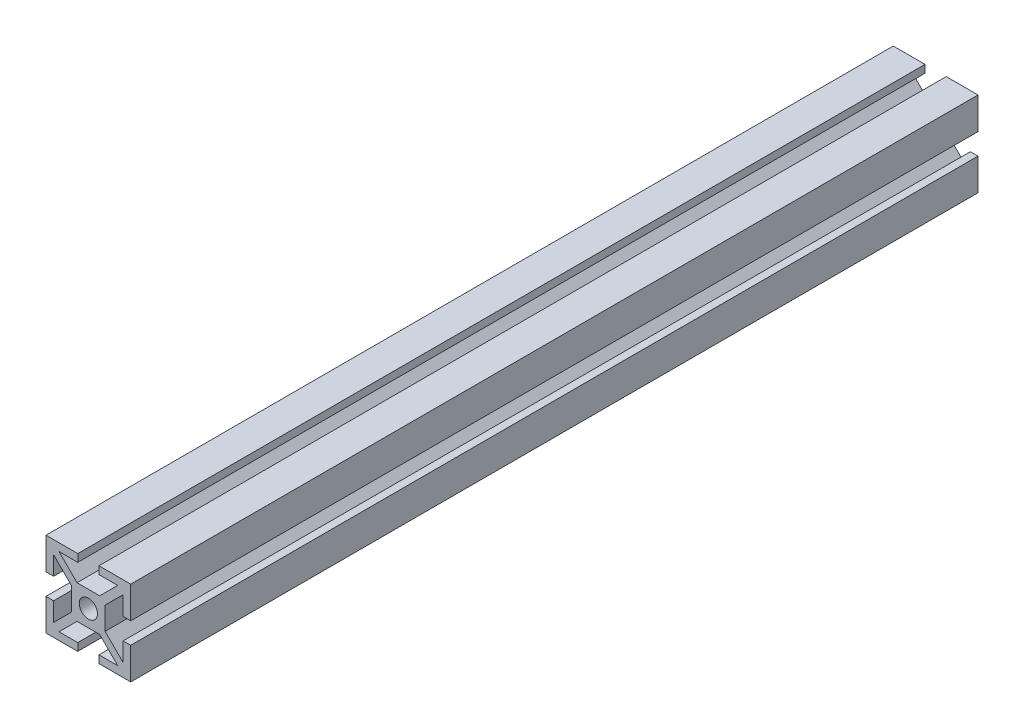
from build123d import *

# Parameters (mm, degrees)
SKETCH2_R           = 2.15
BOSS_EXTRUDE1_DEPTH = 100


with BuildPart() as part:
    # Sketch2 → Boss-Extrude1 (new body, symmetric)
    with BuildSketch(Plane.XY):
        Polygon((-2.5, 10), (-2.5, 8.2), (-6.927207794, 8.2), (-2.677207794, 3.95), (2.677207794, 3.95), (6.927207794, 8.2), (2.5, 8.2), (2.5, 10), (10, 10), (10, 2.5), (8.2, 2.5), (8.2, 6.927207794), (3.95, 2.677207794), (3.95, -2.677207794), (8.2, -6.927207794), (8.2, -2.5), (10, -2.5), (10, -10), (2.5, -10), (2.5, -8.2), (6.927207794, -8.2), (2.677207794, -3.95), (-2.677207794, -3.95), (-6.927207794, -8.2), (-2.5, -8.2), (-2.5, -10), (-10, -10), (-10, -2.5), (-8.2, -2.5), (-8.2, -6.927207794), (-3.95, -2.677207794), (-3.95, 2.677207794), (-8.2, 6.927207794), (-8.2, 2.5), (-10, 2.5), (-10, 10), align=None)
        Circle(SKETCH2_R, mode=Mode.SUBTRACT)
    extrude(amount=BOSS_EXTRUDE1_DEPTH, both=True)


solid = part.part
